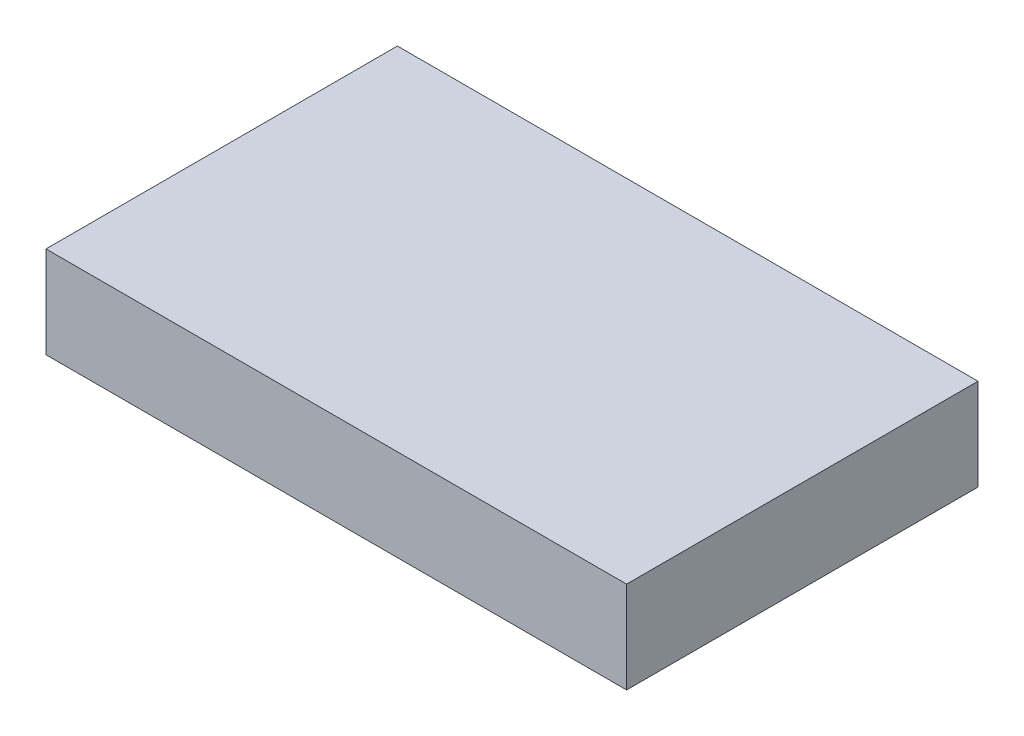
from build123d import *

# Parameters (mm, degrees)
SKETCH1_W           = 38
SKETCH1_H           = 23
BOSS_EXTRUDE1_DEPTH = 6


with BuildPart() as part:
    # Sketch1 → Boss-Extrude1 (new body)
    with BuildSketch(Plane(origin=(0, 0, 0), x_dir=(1, 0, 0), z_dir=(0, 1, 0))):
        Rectangle(SKETCH1_W, SKETCH1_H)
    extrude(amount=BOSS_EXTRUDE1_DEPTH)


solid = part.part
